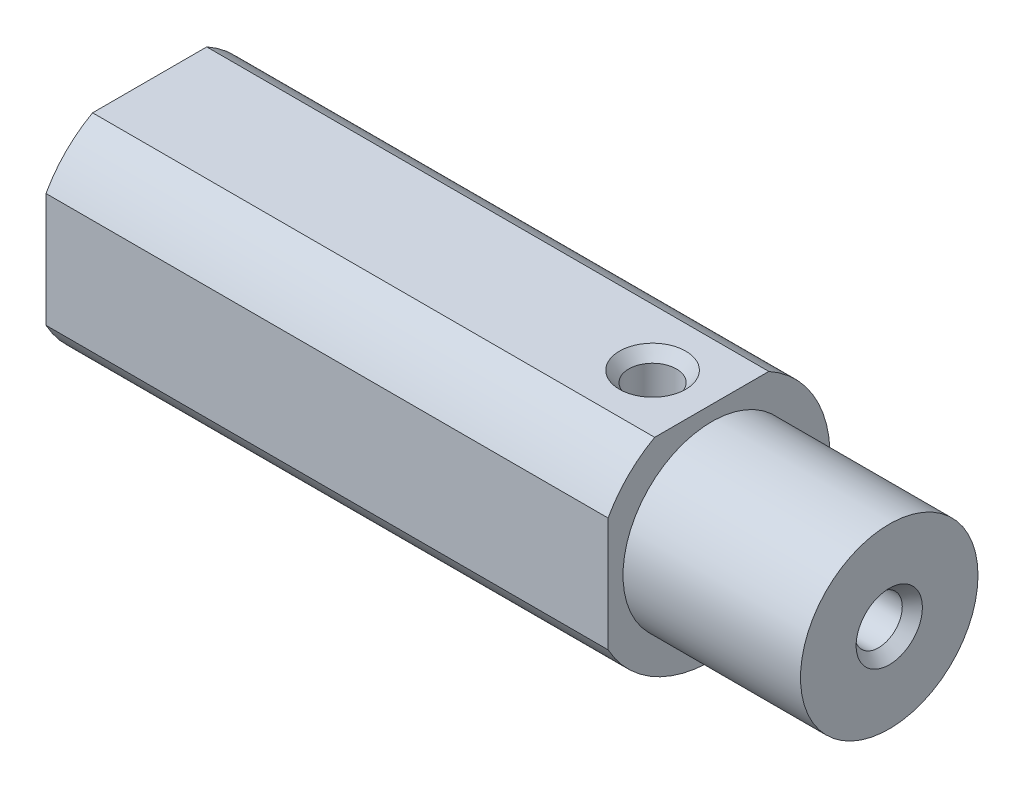
from build123d import *

# Parameters (mm, degrees)
SKETCH1_R                         = 12.7
BOSS_EXTRUDE1_DEPTH               = 79.375
SKETCH2_R                         = 21.293421543
SKETCH2_R_2                       = 9.525
CUT_EXTRUDE1_DEPTH                = 19.05
SKETCH3_W                         = 88.347660667
SKETCH3_H                         = 62.084650607
CUT_EXTRUDE2_DEPTH                = 7.62
SKETCH7_W                         = 118.824828897
SKETCH7_H                         = 51.847980611
CUT_EXTRUDE5_DEPTH                = 25.4
F_1_4_20_TAPPED_HOLE2_D           = 5.1054
F_1_4_20_TAPPED_HOLE2_DEPTH       = 16.002
F_1_4_20_TAPPED_HOLE2_CSINK_D     = 7.112
F_1_4_20_TAPPED_HOLE2_CSINK_ANGLE = 82
F_1_4_20_TAPPED_HOLE2_TIP         = 1.533816902
F_1_4_20_TAPPED_HOLE3_D           = 5.1054
F_1_4_20_TAPPED_HOLE3_DEPTH       = 16.002
F_1_4_20_TAPPED_HOLE3_CSINK_D     = 7.112
F_1_4_20_TAPPED_HOLE3_CSINK_ANGLE = 82
F_1_4_20_TAPPED_HOLE3_TIP         = 1.533816902


with BuildPart() as part:
    # Sketch1 → Boss-Extrude1 (new body)
    with BuildSketch(Plane(origin=(0, 0, 0), x_dir=(0, 0, -1), z_dir=(1, 0, 0))):
        Circle(SKETCH1_R)
    extrude(amount=-BOSS_EXTRUDE1_DEPTH)

    # Sketch2 → Cut-Extrude1 (cut)
    with BuildSketch(Plane(origin=(0, 0, 0), x_dir=(0, 0, -1), z_dir=(1, 0, 0))):
        Circle(SKETCH2_R)
        Circle(SKETCH2_R_2, mode=Mode.SUBTRACT)
    extrude(amount=-CUT_EXTRUDE1_DEPTH, mode=Mode.SUBTRACT)

    # Sketch3 → Cut-Extrude2 (cut)
    with BuildSketch(Plane(origin=(0, 12.401228443, 11.1252), x_dir=(1, 0, 0), z_dir=(0, 0, 1))):
        with Locations((-47.069787049, -6.880973923)):
            Rectangle(SKETCH3_W, SKETCH3_H)
    extrude(amount=CUT_EXTRUDE2_DEPTH, mode=Mode.SUBTRACT)

    # Sketch7 → Cut-Extrude5 (cut)
    with BuildSketch(Plane(origin=(0, 11.1252, 0), x_dir=(-1, 0, 0), z_dir=(0, 1, 0))):
        with Locations((37.000899043, -1.114295637)):
            Rectangle(SKETCH7_W, SKETCH7_H)
    extrude(amount=CUT_EXTRUDE5_DEPTH, mode=Mode.SUBTRACT)

    # 1/4-20 Tapped Hole2
    with Locations(Plane(origin=(0, 11.1252, 0), x_dir=(-1, 0, 0), z_dir=(0, 1, 0))):
        with Locations((25.4, 0)):
            CounterSinkHole(F_1_4_20_TAPPED_HOLE2_D / 2, F_1_4_20_TAPPED_HOLE2_CSINK_D / 2, depth=F_1_4_20_TAPPED_HOLE2_DEPTH, counter_sink_angle=F_1_4_20_TAPPED_HOLE2_CSINK_ANGLE)
            with Locations((0, 0, -(F_1_4_20_TAPPED_HOLE2_DEPTH + F_1_4_20_TAPPED_HOLE2_TIP / 2))):  # 118° drill point
                Cone(0, F_1_4_20_TAPPED_HOLE2_D / 2, F_1_4_20_TAPPED_HOLE2_TIP, mode=Mode.SUBTRACT)

    # 1/4-20 Tapped Hole3
    with Locations(Plane(origin=(0, 0, 0), x_dir=(0, 0, -1), z_dir=(1, 0, 0))):
        with Locations((0, 0)):
            CounterSinkHole(F_1_4_20_TAPPED_HOLE3_D / 2, F_1_4_20_TAPPED_HOLE3_CSINK_D / 2, depth=F_1_4_20_TAPPED_HOLE3_DEPTH, counter_sink_angle=F_1_4_20_TAPPED_HOLE3_CSINK_ANGLE)
            with Locations((0, 0, -(F_1_4_20_TAPPED_HOLE3_DEPTH + F_1_4_20_TAPPED_HOLE3_TIP / 2))):  # 118° drill point
                Cone(0, F_1_4_20_TAPPED_HOLE3_D / 2, F_1_4_20_TAPPED_HOLE3_TIP, mode=Mode.SUBTRACT)


solid = part.part
